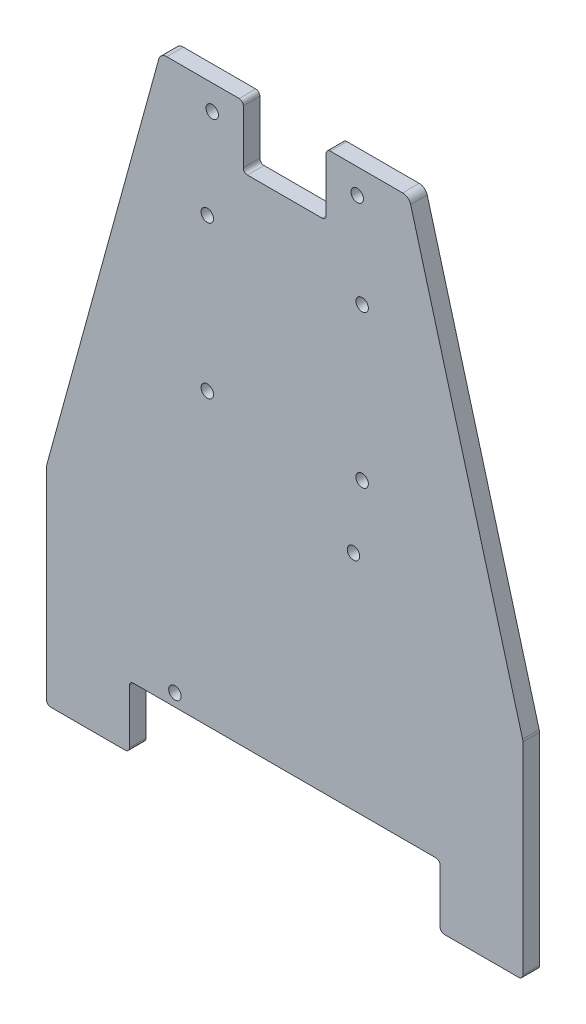
from build123d import *

# Parameters (mm, degrees)
SKETCH6_W           = 115
SKETCH6_H           = 150
BOSS_EXTRUDE2_DEPTH = 4
SKETCH7_W           = 75
SKETCH7_H           = 15
CUT_EXTRUDE1_DEPTH  = 5
FILLET1_R           = 1
SKETCH8_W           = 10
SKETCH8_H           = 15
CUT_EXTRUDE2_DEPTH  = 5
FILLET2_R           = 1
CUT_EXTRUDE3_DEPTH  = 5
FILLET3_R           = 2
SKETCH14_R          = 1.5
CUT_EXTRUDE4_DEPTH  = 5
SKETCH17_R          = 1.5
CUT_EXTRUDE6_DEPTH  = 5
SKETCH18_R          = 1.5
CUT_EXTRUDE7_DEPTH  = 5


with BuildPart() as part:
    # Sketch6 → Boss-Extrude2 (new body)
    with BuildSketch(Plane.XY):
        with Locations((-57.5, 75)):
            Rectangle(SKETCH6_W, SKETCH6_H)
    extrude(amount=BOSS_EXTRUDE2_DEPTH)

    # Sketch7 → Cut-Extrude1 (cut, through all)
    with BuildSketch(Plane.XY.offset(4)):
        with Locations((-57.5, 7.5)):
            Rectangle(SKETCH7_W, SKETCH7_H)
    extrude(amount=-CUT_EXTRUDE1_DEPTH, mode=Mode.SUBTRACT)

    # Fillet1
    fillet1_edges = [part.edges().sort_by_distance(p)[0] for p in [
        (-95, 0, 2),
        (-95, 15, 2),
        (-20, 15, 2),
        (-20, 0, 2),
        (0, 0, 2),
        (-115, 0, 2),
    ]]
    fillet(fillet1_edges, radius=FILLET1_R)

    # Sketch8 → Cut-Extrude2 (cut, through all)
    with BuildSketch(Plane.XY.offset(4)):
        with Locations((-62.5, 142.5)):
            Rectangle(SKETCH8_W, SKETCH8_H)
        with Locations((-52.5, 142.5)):
            Rectangle(SKETCH8_W, SKETCH8_H)
    extrude(amount=-CUT_EXTRUDE2_DEPTH, mode=Mode.SUBTRACT)

    # Fillet2
    fillet2_edges = [part.edges().sort_by_distance(p)[0] for p in [
        (-67.5, 135, 2),
        (-67.5, 150, 2),
        (-47.5, 150, 2),
        (-47.5, 135, 2),
    ]]
    fillet(fillet2_edges, radius=FILLET2_R)

    # Sketch11 → Cut-Extrude3 (cut, through all)
    with BuildSketch(Plane.XY.offset(4)):
        Polygon((-87.5, 150), (-115, 50), (-115, 150), align=None)
        Polygon((0, 50), (0, 150), (-27.5, 150), align=None)
    extrude(amount=-CUT_EXTRUDE3_DEPTH, mode=Mode.SUBTRACT)

    # Fillet3
    fillet3_edges = [part.edges().sort_by_distance(p)[0] for p in [
        (0, 50, 2),
        (-27.5, 150, 2),
        (-87.5, 150, 2),
        (-115, 50, 2),
    ]]
    fillet(fillet3_edges, radius=FILLET3_R)

    # Sketch14 → Cut-Extrude4 (cut, through all)
    with BuildSketch(Plane(origin=(0, 0, 0), x_dir=(-1, 0, 0), z_dir=(0, 0, -1))):
        with Locations((40, 144)):
            Circle(SKETCH14_R)
        with Locations((75, 144)):
            Circle(SKETCH14_R)
    extrude(amount=-CUT_EXTRUDE4_DEPTH, mode=Mode.SUBTRACT)

    # Sketch17 → Cut-Extrude6 (cut, through all)
    with BuildSketch(Plane.XY.offset(4)):
        with Locations((-76.19, 121.74)):
            Circle(SKETCH17_R)
        with Locations((-38.81, 121.74)):
            Circle(SKETCH17_R)
        with Locations((-76.19, 85)):
            Circle(SKETCH17_R)
        with Locations((-38.81, 85)):
            Circle(SKETCH17_R)
    extrude(amount=-CUT_EXTRUDE6_DEPTH, mode=Mode.SUBTRACT)

    # Sketch18 → Cut-Extrude7 (cut, through all)
    with BuildSketch(Plane.XY.offset(4)):
        with Locations((-84, 18)):
            Circle(SKETCH18_R)
        with Locations((-40.9, 68.8)):
            Circle(SKETCH18_R)
    extrude(amount=-CUT_EXTRUDE7_DEPTH, mode=Mode.SUBTRACT)


solid = part.part
